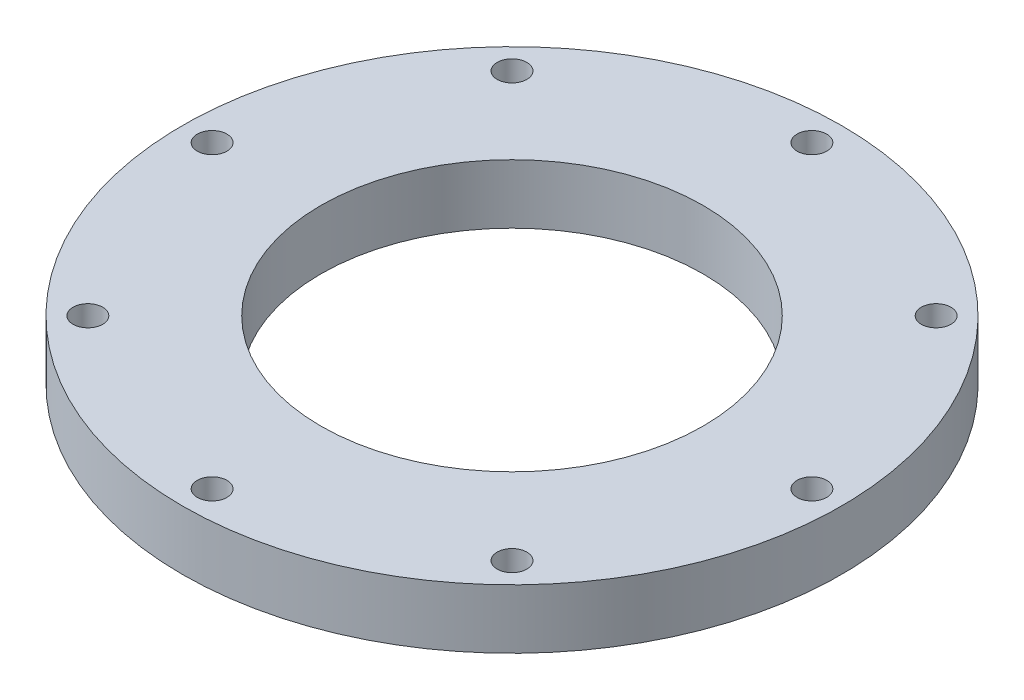
from build123d import *

# Parameters (mm, degrees)
SKETCH1_R           = 50
SKETCH1_R_2         = 29
BOSS_EXTRUDE1_DEPTH = 4.5
SKETCH2_R           = 2.25
CUT_EXTRUDE1_DEPTH  = 10
CIRPATTERN1_COUNT   = 8


with BuildPart() as part:
    # Sketch1 → Boss-Extrude1 (new body, symmetric)
    with BuildSketch(Plane(origin=(0, 0, 0), x_dir=(1, 0, 0), z_dir=(0, 1, 0))):
        Circle(SKETCH1_R)
        Circle(SKETCH1_R_2, mode=Mode.SUBTRACT)
    extrude(amount=BOSS_EXTRUDE1_DEPTH, both=True)

    # Sketch2 → Cut-Extrude1 (cut, through all)
    with BuildSketch(Plane(origin=(0, 4.5, 0), x_dir=(1, 0, 0), z_dir=(0, 1, 0))):
        with Locations((0, 45.5)):
            Circle(SKETCH2_R)
    cut_extrude1 = extrude(amount=-CUT_EXTRUDE1_DEPTH, mode=Mode.SUBTRACT)

    # CirPattern1: Cut-Extrude1 ×8 about axis
    cirpattern1_axis = Axis((0, 0, 0), (0, 1, 0))
    for i in range(1, CIRPATTERN1_COUNT):
        add(cut_extrude1.rotate(cirpattern1_axis, i * 360 / CIRPATTERN1_COUNT), mode=Mode.SUBTRACT)


solid = part.part
